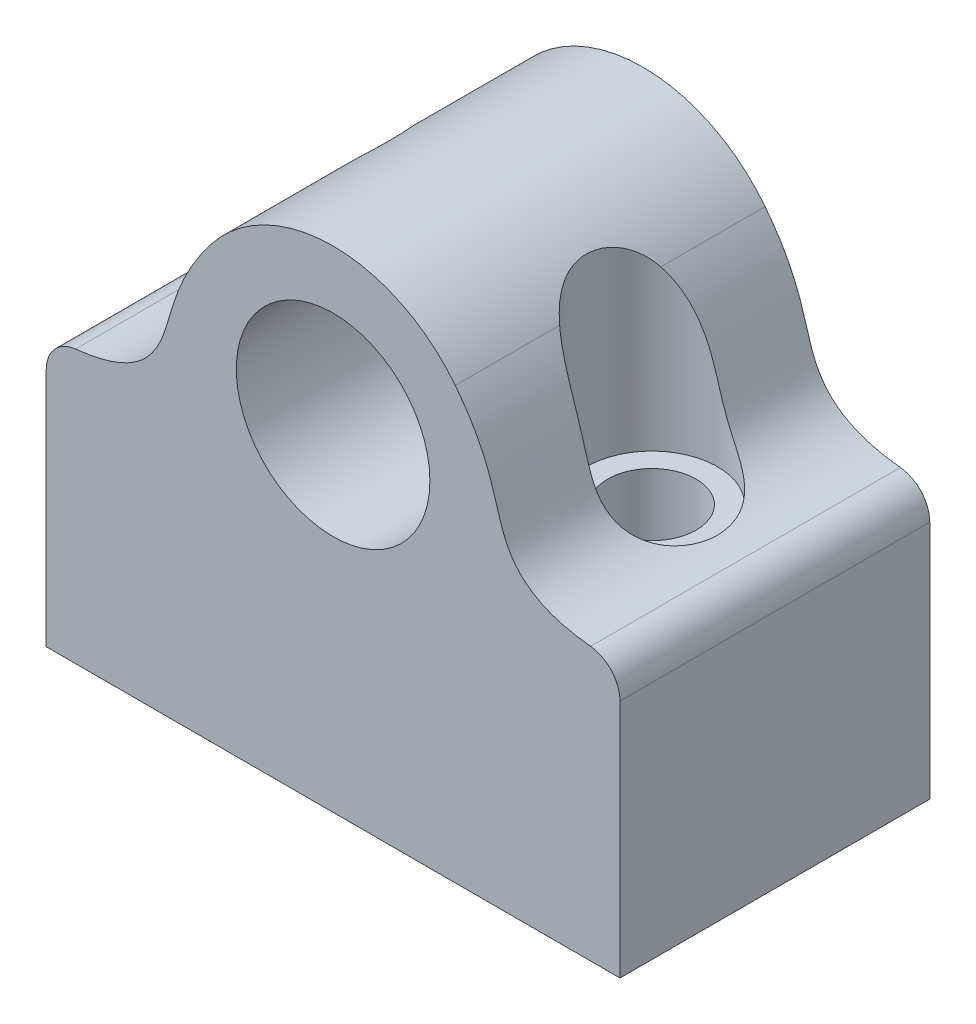
from build123d import *

# Parameters (mm, degrees)
SKETCH1_R           = 7.5
BOSS_EXTRUDE1_DEPTH = 12
SKETCH3_R           = 3.425
CUT_EXTRUDE1_DEPTH  = 23.0000001
FILLET1_R           = 2.54
SKETCH4_R           = 5.08
CUT_EXTRUDE2_DEPTH  = 18.000000194
SKETCH5_W           = 44.45
SKETCH5_H           = 24
SKETCH5_R           = 3.425
BOSS_EXTRUDE2_DEPTH = 16


with BuildPart() as part:
    # Sketch1 → Boss-Extrude1 (new body, symmetric)
    with BuildSketch(Plane.XY):
        with BuildLine():
            Line((22.225, -10), (-22.225, -10))
            Line((-22.225, -10), (-22.225, -5))
            add(Edge.make_bspline(
                [(-22.225, -5), (-16.631079064, -4.98201906), (-12.322747723, -1.728386223), (-12.530535341, 3.440374129), (-9.467504716, 7.373354356)],
                knots=[0, 0, 0, 0, 0.501954987, 1, 1, 1, 1], degree=3))
            ThreePointArc((-9.467504716, 7.373354356), (0, 12), (9.467504716, 7.373354356))
            add(Edge.make_bspline(
                [(22.225, -5), (16.631079064, -4.98201906), (12.322747723, -1.728386223), (12.530535341, 3.440374129), (9.467504716, 7.373354356)],
                knots=[0, 0, 0, 0, 0.501954987, 1, 1, 1, 1], degree=3))
            Line((22.225, -5), (22.225, -10))
        make_face()
        Circle(SKETCH1_R, mode=Mode.SUBTRACT)
    extrude(amount=BOSS_EXTRUDE1_DEPTH, both=True)

    # Sketch3 → Cut-Extrude1 (cut, through all)
    with BuildSketch(Plane.XZ.offset(10)):
        with Locations((-12.7, 0)):
            Circle(SKETCH3_R)
        with Locations((12.7, 0)):
            Circle(SKETCH3_R)
    extrude(amount=-CUT_EXTRUDE1_DEPTH, mode=Mode.SUBTRACT)

    # Fillet1
    fillet1_edges = [part.edges().sort_by_distance(p)[0] for p in [
        (22.225, -5, -6),
        (-22.225, -5, 6),
    ]]
    fillet(fillet1_edges, radius=FILLET1_R)

    # Sketch4 → Cut-Extrude2 (cut, through all)
    with BuildSketch(Plane(origin=(0, -5.000000094, 0), x_dir=(-1, 0, 0), z_dir=(0, -1, 0))):
        with Locations((12.7, 0)):
            Circle(SKETCH4_R)
        with Locations((-12.7, 0)):
            Circle(SKETCH4_R)
    extrude(amount=-CUT_EXTRUDE2_DEPTH, mode=Mode.SUBTRACT)

    # Sketch5 → Boss-Extrude2 (add)
    with BuildSketch(Plane.XZ.offset(10)):
        Rectangle(SKETCH5_W, SKETCH5_H)
        with Locations((12.7, 0)):
            Circle(SKETCH5_R, mode=Mode.SUBTRACT)
        with Locations((-12.7, 0)):
            Circle(SKETCH5_R, mode=Mode.SUBTRACT)
    extrude(amount=BOSS_EXTRUDE2_DEPTH)


solid = part.part
